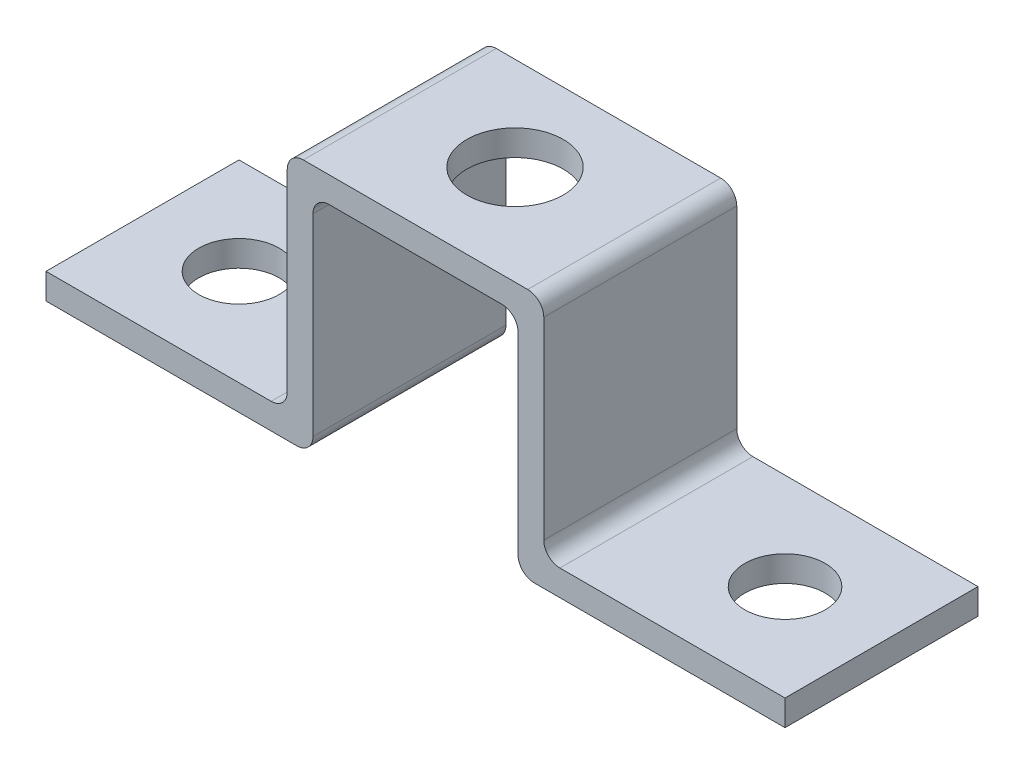
from build123d import *

# Parameters (mm, degrees)
BOSS_EXTRUDE1_DEPTH = 12
SKETCH2_R           = 2.5
CUT_EXTRUDE2_DEPTH  = 1.6
SKETCH3_R           = 3
CUT_EXTRUDE3_DEPTH  = 1.6
FILLET2_R           = 1
FILLET3_R           = 1
FILLET4_R           = 1
FILLET5_R           = 1
FILLET6_R           = 1
FILLET7_R           = 1
FILLET8_R           = 1
FILLET9_R           = 1


with BuildPart() as part:
    # Sketch1 → Boss-Extrude1 (new body)
    with BuildSketch(Plane.XY):
        Polygon((-22.976789636, 1.251050745), (-7.976789636, 1.251050745), (-7.976789636, 15.251050745), (7.976789636, 15.251050745), (7.976789636, 1.251050745), (22.976789636, 1.251050745), (22.976789636, -0.348949255), (6.376789636, -0.348949255), (6.376789636, 13.651050745), (-6.376789636, 13.651050745), (-6.376789636, -0.348949255), (-22.976789636, -0.348949255), align=None)
    extrude(amount=BOSS_EXTRUDE1_DEPTH)

    # Sketch2 → Cut-Extrude2 (cut)
    with BuildSketch(Plane(origin=(0, 1.251050745, 0), x_dir=(1, 0, 0), z_dir=(0, 1, 0))):
        with Locations(Location((-16.976789636, -6, 0), (0, 0, 270))):  # turned: the seam where the file's is
            Circle(SKETCH2_R)
        with Locations(Location((16.976789636, -6, 0), (0, 0, 270))):  # turned: the seam where the file's is
            Circle(SKETCH2_R)
    extrude(amount=-CUT_EXTRUDE2_DEPTH, mode=Mode.SUBTRACT)

    # Sketch3 → Cut-Extrude3 (cut)
    with BuildSketch(Plane(origin=(0, 15.251050745, 0), x_dir=(1, 0, 0), z_dir=(0, 1, 0))):
        with Locations(Location((0, -5.812620311, 0), (0, 0, 270))):  # turned: the seam where the file's is
            Circle(SKETCH3_R)
    extrude(amount=-CUT_EXTRUDE3_DEPTH, mode=Mode.SUBTRACT)

    # Fillet2
    fillet2_edges = [part.edges().sort_by_distance(p)[0] for p in [
        (-7.976789636, 15.251050745, 6),
    ]]
    fillet(fillet2_edges, radius=FILLET2_R)

    # Fillet3
    fillet3_edges = [part.edges().sort_by_distance(p)[0] for p in [
        (7.976789636, 15.251050745, 6),
    ]]
    fillet(fillet3_edges, radius=FILLET3_R)

    # Fillet4
    fillet4_edges = [part.edges().sort_by_distance(p)[0] for p in [
        (-6.376789636, 13.651050745, 6),
    ]]
    fillet(fillet4_edges, radius=FILLET4_R)

    # Fillet5
    fillet5_edges = [part.edges().sort_by_distance(p)[0] for p in [
        (-6.376789636, -0.348949255, 6),
    ]]
    fillet(fillet5_edges, radius=FILLET5_R)

    # Fillet6
    fillet6_edges = [part.edges().sort_by_distance(p)[0] for p in [
        (6.376789636, -0.348949255, 6),
    ]]
    fillet(fillet6_edges, radius=FILLET6_R)

    # Fillet7
    fillet7_edges = [part.edges().sort_by_distance(p)[0] for p in [
        (6.376789636, 13.651050745, 6),
    ]]
    fillet(fillet7_edges, radius=FILLET7_R)

    # Fillet8
    fillet8_edges = [part.edges().sort_by_distance(p)[0] for p in [
        (-7.976789636, 1.251050745, 6),
    ]]
    fillet(fillet8_edges, radius=FILLET8_R)

    # Fillet9
    fillet9_edges = [part.edges().sort_by_distance(p)[0] for p in [
        (7.976789636, 1.251050745, 6),
    ]]
    fillet(fillet9_edges, radius=FILLET9_R)


solid = part.part
